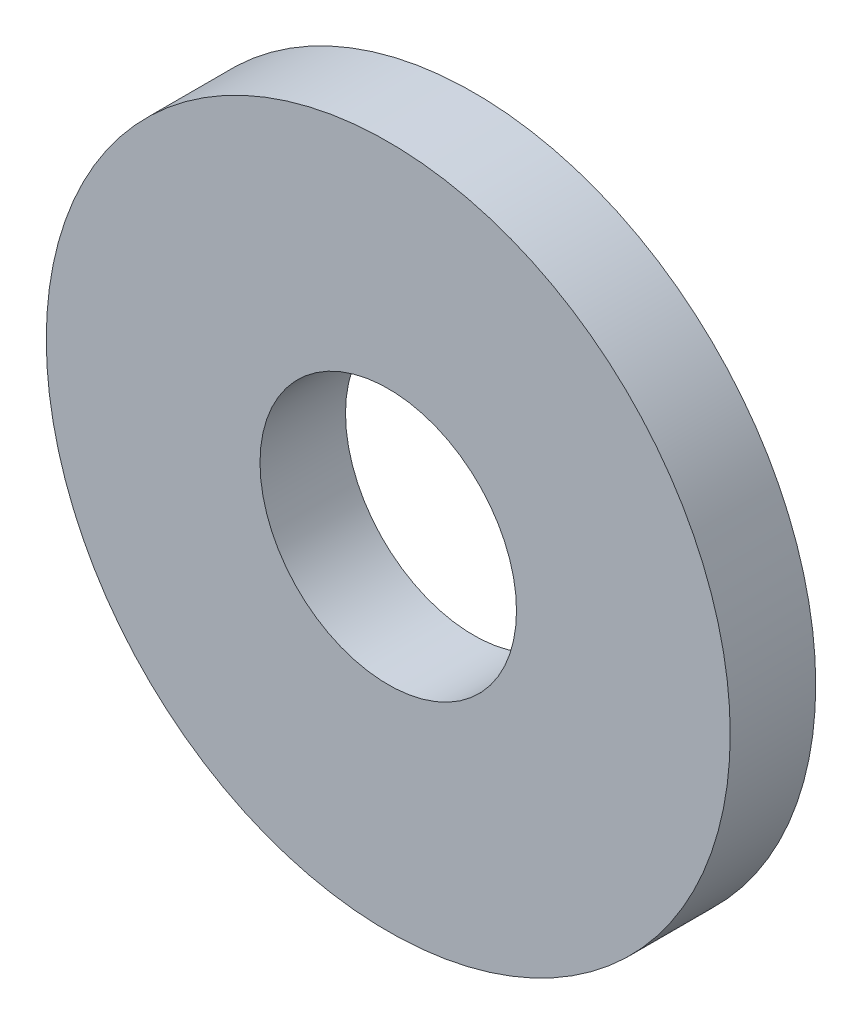
from build123d import *

# Parameters (mm, degrees)
CROQUIS1_R              = 12.7
CROQUIS1_R_2            = 4.7625
SALIENTE_EXTRUIR1_DEPTH = 3.175


with BuildPart() as part:
    # Croquis1 → Saliente-Extruir1 (new body)
    with BuildSketch(Plane.XY):
        Circle(CROQUIS1_R)
        Circle(CROQUIS1_R_2, mode=Mode.SUBTRACT)
    extrude(amount=SALIENTE_EXTRUIR1_DEPTH)


solid = part.part
